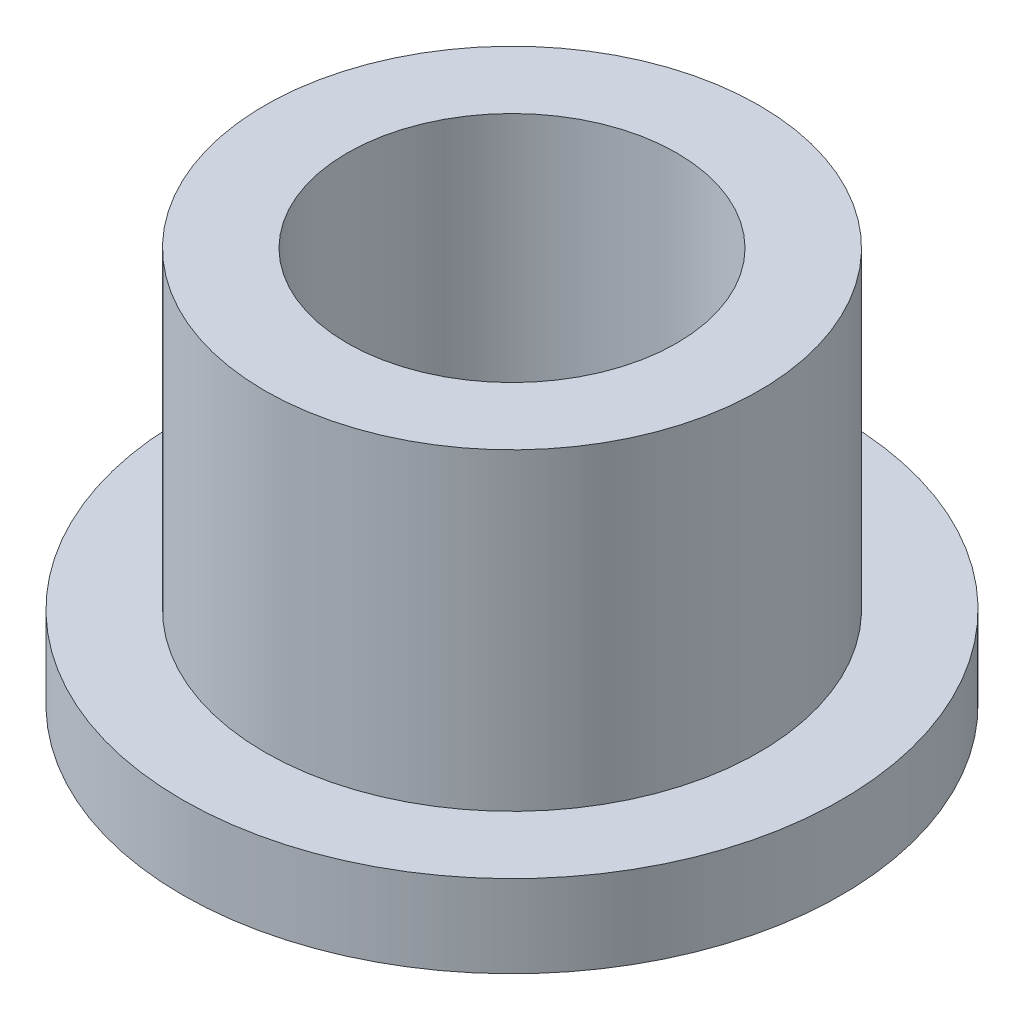
from build123d import *

# Parameters (mm, degrees)
SKETCH2_R           = 4.7625
SKETCH2_R_2         = 3.175
BOSS_EXTRUDE1_DEPTH = 7.62
SKETCH3_R           = 6.35
SKETCH3_R_2         = 4.7625
BOSS_EXTRUDE2_DEPTH = 1.5875


with BuildPart() as part:
    # Sketch2 → Boss-Extrude1 (new body)
    with BuildSketch(Plane(origin=(0, 0, 0), x_dir=(1, 0, 0), z_dir=(0, 1, 0))):
        Circle(SKETCH2_R)
        Circle(SKETCH2_R_2, mode=Mode.SUBTRACT)
    extrude(amount=BOSS_EXTRUDE1_DEPTH)

    # Sketch3 → Boss-Extrude2 (add)
    with BuildSketch(Plane(origin=(0, 0, 0), x_dir=(1, 0, 0), z_dir=(0, 1, 0))):
        Circle(SKETCH3_R)
        Circle(SKETCH3_R_2, mode=Mode.SUBTRACT)
    extrude(amount=BOSS_EXTRUDE2_DEPTH)


solid = part.part
